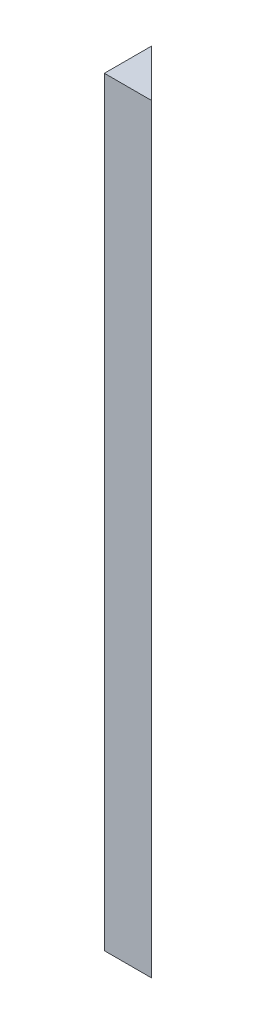
from build123d import *

# Parameters (mm, degrees)
BOSS_EXTRUDE1_DEPTH = 182


with BuildPart() as part:
    # Sketch2 → Boss-Extrude1 (new body)
    with BuildSketch(Plane(origin=(0, 0, 0), x_dir=(1, 0, 0), z_dir=(0, 1, 0))):
        Polygon((0, 0), (11.31, 0), (0, 11.31), align=None)
    extrude(amount=BOSS_EXTRUDE1_DEPTH)


solid = part.part
